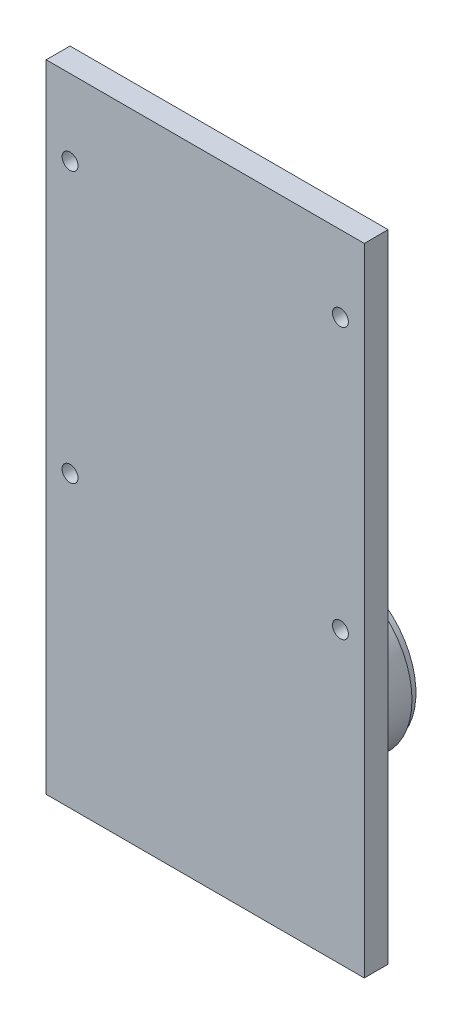
from build123d import *

# Parameters (mm, degrees)
SKETCH1_W           = 40
SKETCH1_H           = 80
BOSS_EXTRUDE1_DEPTH = 3
SKETCH2_R           = 1
CUT_EXTRUDE1_DEPTH  = 3
SKETCH3_R           = 15
BOSS_EXTRUDE2_DEPTH = 3
FILLET1_R           = 1.2
SKETCH4_R           = 10
BOSS_EXTRUDE3_DEPTH = 10
SKETCH14_R          = 9.5
BOSS_EXTRUDE4_DEPTH = 1
SKETCH15_R          = 7.5
CUT_EXTRUDE7_DEPTH  = 1


with BuildPart() as part:
    # Sketch1 → Boss-Extrude1 (new body)
    with BuildSketch(Plane.XY):
        with Locations((20, 40)):
            Rectangle(SKETCH1_W, SKETCH1_H)
    extrude(amount=BOSS_EXTRUDE1_DEPTH)

    # Sketch2 → Cut-Extrude1 (cut)
    with BuildSketch(Plane.XY.offset(3)):
        with Locations((3, 70.446149139)):
            Circle(SKETCH2_R)
        with Locations((3, 36.446149139)):
            Circle(SKETCH2_R)
        with Locations((37, 70.446149139)):
            Circle(SKETCH2_R)
        with Locations((37, 36.446149139)):
            Circle(SKETCH2_R)
    extrude(amount=-CUT_EXTRUDE1_DEPTH, mode=Mode.SUBTRACT)

    # Sketch3 → Boss-Extrude2 (add)
    with BuildSketch(Plane(origin=(0, 0, 0), x_dir=(-1, 0, 0), z_dir=(0, 0, -1))):
        with Locations((-20, 17.303489874)):
            Circle(SKETCH3_R)
    extrude(amount=BOSS_EXTRUDE2_DEPTH)

    # Fillet1
    fillet1_edges = [part.edges().sort_by_distance(p)[0] for p in [
        (35, 17.303489874, 0),
    ]]
    fillet(fillet1_edges, radius=FILLET1_R)

    # Sketch4 → Boss-Extrude3 (add)
    with BuildSketch(Plane(origin=(0, 0, -3), x_dir=(-1, 0, 0), z_dir=(0, 0, -1))):
        with Locations((-20, 17.303489874)):
            Circle(SKETCH4_R)
    extrude(amount=BOSS_EXTRUDE3_DEPTH)

    # Sketch10 → Cut-Revolve2 (revolve, cut)
    with BuildSketch(Plane(origin=(0, 0, -13), x_dir=(-1, 0, 0), z_dir=(0, 0, -1))):
        with BuildLine():
            Line((-20, 25.837066369), (-20, 8.769913378))
            ThreePointArc((-20, 8.769913378), (-11.466423505, 17.303489874), (-20, 25.837066369))
        make_face()
    revolve(axis=Axis((20, 25.837066369, -13), (0, -1, 0)), mode=Mode.SUBTRACT)

    # Sketch14 → Boss-Extrude4 (add)
    with BuildSketch(Plane(origin=(0, 0, -13), x_dir=(-1, 0, 0), z_dir=(0, 0, -1))):
        with Locations((-20, 17.303489874)):
            Circle(SKETCH14_R)
    extrude(amount=BOSS_EXTRUDE4_DEPTH)

    # Sketch15 → Cut-Extrude7 (cut)
    with BuildSketch(Plane(origin=(0, 0, -14), x_dir=(-1, 0, 0), z_dir=(0, 0, -1))):
        with Locations((-20, 17.303489874)):
            Circle(SKETCH15_R)
    extrude(amount=-CUT_EXTRUDE7_DEPTH, mode=Mode.SUBTRACT)


solid = part.part
